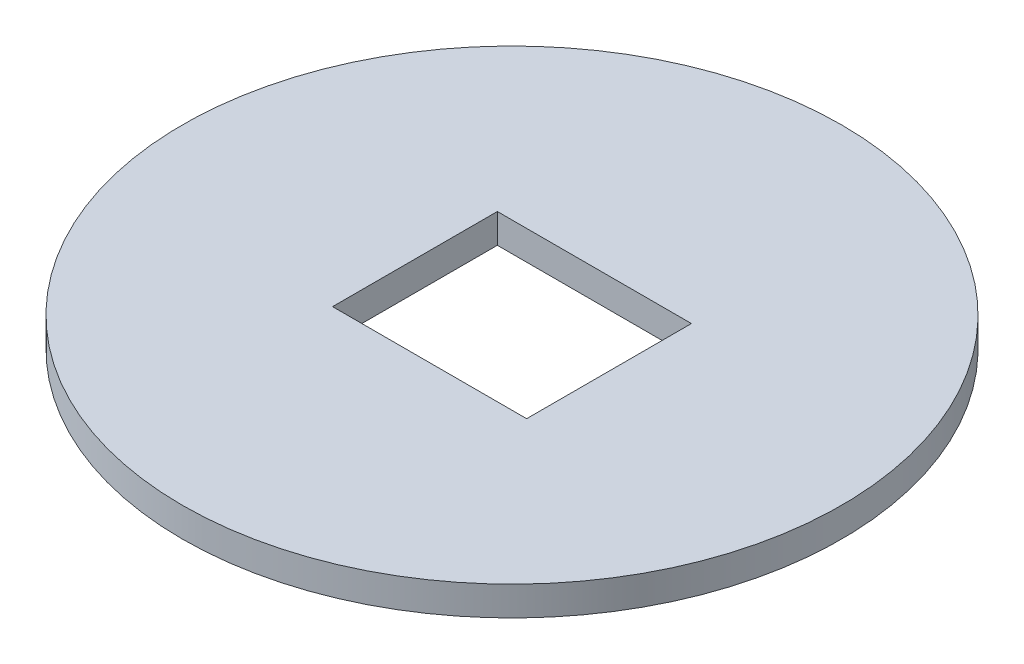
from build123d import *

# Parameters (mm, degrees)
SKETCH2_R      = 90
SKETCH2_W      = 53
SKETCH2_H      = 45
EXTRUDE1_DEPTH = 8


with BuildPart() as part:
    # Sketch2 → Extrude1 (new body)
    with BuildSketch(Plane(origin=(0, 0, 0), x_dir=(1, 0, 0), z_dir=(0, 1, 0))):
        Circle(SKETCH2_R)
        Rectangle(SKETCH2_W, SKETCH2_H, mode=Mode.SUBTRACT)
    extrude(amount=EXTRUDE1_DEPTH)


solid = part.part
